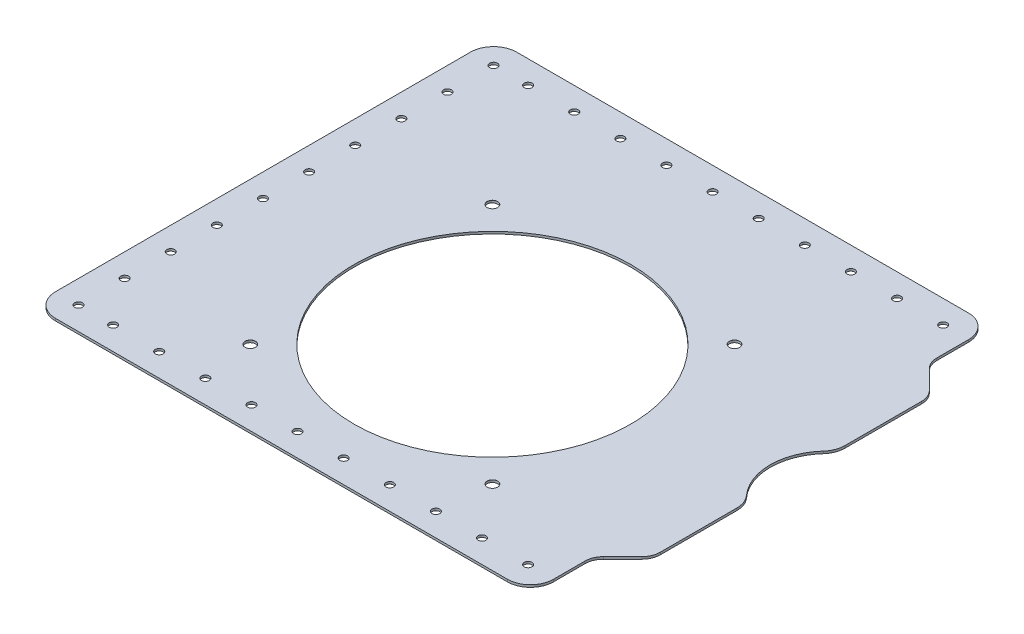
from build123d import *

# Parameters (mm, degrees)
SKETCH1_W                      = 229
SKETCH1_H                      = 200
BOSS_EXTRUDE1_DEPTH            = 1
CUT_EXTRUDE1_DEPTH             = 2
FILLET1_R                      = 8
FILLET2_R                      = 10
M3_CLEARANCE_HOLE1_AT_2_COUNT  = 2
M3_CLEARANCE_HOLE1_AT_2_PITCH  = 20
M3_CLEARANCE_HOLE1_AT_3_COUNT  = 2
M3_CLEARANCE_HOLE1_AT_3_PITCH  = 40
M3_CLEARANCE_HOLE1_AT_4_COUNT  = 2
M3_CLEARANCE_HOLE1_AT_4_PITCH  = 60
M3_CLEARANCE_HOLE1_AT_5_COUNT  = 2
M3_CLEARANCE_HOLE1_AT_5_PITCH  = 80
M3_CLEARANCE_HOLE1_AT_6_COUNT  = 2
M3_CLEARANCE_HOLE1_AT_6_PITCH  = 100
M3_CLEARANCE_HOLE1_AT_7_COUNT  = 2
M3_CLEARANCE_HOLE1_AT_7_PITCH  = 120
M3_CLEARANCE_HOLE1_AT_8_COUNT  = 2
M3_CLEARANCE_HOLE1_AT_8_PITCH  = 140
M3_CLEARANCE_HOLE1_AT_9_COUNT  = 2
M3_CLEARANCE_HOLE1_AT_9_PITCH  = 160
M3_CLEARANCE_HOLE1_AT_10_COUNT = 2
M3_CLEARANCE_HOLE1_AT_10_PITCH = 180
M3_CLEARANCE_HOLE2_AT_2_COUNT  = 2
M3_CLEARANCE_HOLE2_AT_2_PITCH  = 20
M3_CLEARANCE_HOLE2_AT_3_COUNT  = 2
M3_CLEARANCE_HOLE2_AT_3_PITCH  = 40
M3_CLEARANCE_HOLE2_AT_4_COUNT  = 2
M3_CLEARANCE_HOLE2_AT_4_PITCH  = 60
M3_CLEARANCE_HOLE2_AT_5_COUNT  = 2
M3_CLEARANCE_HOLE2_AT_5_PITCH  = 80
M3_CLEARANCE_HOLE2_AT_6_COUNT  = 2
M3_CLEARANCE_HOLE2_AT_6_PITCH  = 100
M3_CLEARANCE_HOLE2_AT_7_COUNT  = 2
M3_CLEARANCE_HOLE2_AT_7_PITCH  = 120
M3_CLEARANCE_HOLE2_AT_8_COUNT  = 2
M3_CLEARANCE_HOLE2_AT_8_PITCH  = 140
M3_CLEARANCE_HOLE2_AT_9_COUNT  = 2
M3_CLEARANCE_HOLE2_AT_9_PITCH  = 160
M3_CLEARANCE_HOLE2_AT_10_COUNT = 2
M3_CLEARANCE_HOLE2_AT_10_PITCH = 180
M3_CLEARANCE_HOLE2_AT_11_COUNT = 2
M3_CLEARANCE_HOLE2_AT_11_PITCH = 254.558441227
M3_CLEARANCE_HOLE2_AT_12_COUNT = 2
M3_CLEARANCE_HOLE2_AT_12_PITCH = 240.831891576
M3_CLEARANCE_HOLE2_AT_13_COUNT = 2
M3_CLEARANCE_HOLE2_AT_13_PITCH = 228.03508502
M3_CLEARANCE_HOLE2_AT_14_COUNT = 2
M3_CLEARANCE_HOLE2_AT_14_PITCH = 216.333076528
M3_CLEARANCE_HOLE2_AT_15_COUNT = 2
M3_CLEARANCE_HOLE2_AT_15_PITCH = 205.91260282
M3_CLEARANCE_HOLE2_AT_16_COUNT = 2
M3_CLEARANCE_HOLE2_AT_16_PITCH = 196.977156036
M3_CLEARANCE_HOLE2_AT_17_COUNT = 2
M3_CLEARANCE_HOLE2_AT_17_PITCH = 189.73665961
M3_CLEARANCE_HOLE2_AT_18_COUNT = 2
M3_CLEARANCE_HOLE2_AT_18_PITCH = 184.390889146
M3_CLEARANCE_HOLE2_AT_19_COUNT = 2
M3_CLEARANCE_HOLE2_AT_19_PITCH = 181.107702763
M3_CLEARANCE_HOLE2_AT_20_COUNT = 2
M3_CLEARANCE_HOLE2_AT_20_PITCH = 180
SKETCH7_R                      = 25
CUT_EXTRUDE2_DEPTH             = 10
FILLET3_R                      = 10
M4_CLEARANCE_HOLE1_AT_2_COUNT  = 2
M4_CLEARANCE_HOLE1_AT_2_PITCH  = 105
M4_CLEARANCE_HOLE1_AT_3_COUNT  = 2
M4_CLEARANCE_HOLE1_AT_3_PITCH  = 105
M4_CLEARANCE_HOLE1_AT_4_COUNT  = 2
M4_CLEARANCE_HOLE1_AT_4_PITCH  = 148.492424049
SKETCH10_R                     = 60
CUT_EXTRUDE3_DEPTH             = 10


with BuildPart() as part:
    # Sketch1 → Boss-Extrude1 (new body)
    with BuildSketch(Plane(origin=(0, 0, 0), x_dir=(1, 0, 0), z_dir=(0, 1, 0))):
        Rectangle(SKETCH1_W, SKETCH1_H)
    extrude(amount=BOSS_EXTRUDE1_DEPTH)

    # Sketch2 → Cut-Extrude1 (cut, through all)
    with BuildSketch(Plane(origin=(0, 1, 0), x_dir=(1, 0, 0), z_dir=(0, 1, 0))):
        Polygon((114.5, 60), (101.5, 73), (101.5, 100), (114.5, 100), align=None)
        Polygon((101.5, -100), (114.5, -100), (114.5, -60), (101.5, -73), align=None)
    extrude(amount=-CUT_EXTRUDE1_DEPTH, mode=Mode.SUBTRACT)

    # Fillet1
    fillet1_edges = [part.edges().sort_by_distance(p)[0] for p in [
        (114.5, 0.5, -60),
        (101.5, 0.5, -73),
        (101.5, 0.5, 73),
        (114.5, 0.5, 60),
    ]]
    fillet(fillet1_edges, radius=FILLET1_R)

    # Fillet2
    fillet2_edges = [part.edges().sort_by_distance(p)[0] for p in [
        (101.5, 0.5, -100),
        (101.5, 0.5, 100),
        (-114.5, 0.5, 100),
        (-114.5, 0.5, -100),
    ]]
    fillet(fillet2_edges, radius=FILLET2_R)

    # Sketch4 → M3 Clearance Hole1 (revolve, cut)
    with BuildSketch(Plane(origin=(-104.5, 0, -90), x_dir=(0, 0, -1), z_dir=(1, 0, 0))):
        Polygon((0, 0), (0, 1), (1.7, 1), (1.7, 0.025), (1.725, 0), align=None)
    m3_clearance_hole1 = revolve(axis=Axis((-104.5, -6.35, -90), (0, 1, 0)), mode=Mode.SUBTRACT)

    # M3 Clearance Hole1 at 2: M3 Clearance Hole1 ×2
    with Locations(*[(0, 0, i * M3_CLEARANCE_HOLE1_AT_2_PITCH) for i in range(1, M3_CLEARANCE_HOLE1_AT_2_COUNT)]):
        add(m3_clearance_hole1, mode=Mode.SUBTRACT)

    # M3 Clearance Hole1 at 3: M3 Clearance Hole1 ×2
    with Locations(*[(0, 0, i * M3_CLEARANCE_HOLE1_AT_3_PITCH) for i in range(1, M3_CLEARANCE_HOLE1_AT_3_COUNT)]):
        add(m3_clearance_hole1, mode=Mode.SUBTRACT)

    # M3 Clearance Hole1 at 4: M3 Clearance Hole1 ×2
    with Locations(*[(0, 0, i * M3_CLEARANCE_HOLE1_AT_4_PITCH) for i in range(1, M3_CLEARANCE_HOLE1_AT_4_COUNT)]):
        add(m3_clearance_hole1, mode=Mode.SUBTRACT)

    # M3 Clearance Hole1 at 5: M3 Clearance Hole1 ×2
    with Locations(*[(0, 0, i * M3_CLEARANCE_HOLE1_AT_5_PITCH) for i in range(1, M3_CLEARANCE_HOLE1_AT_5_COUNT)]):
        add(m3_clearance_hole1, mode=Mode.SUBTRACT)

    # M3 Clearance Hole1 at 6: M3 Clearance Hole1 ×2
    with Locations(*[(0, 0, i * M3_CLEARANCE_HOLE1_AT_6_PITCH) for i in range(1, M3_CLEARANCE_HOLE1_AT_6_COUNT)]):
        add(m3_clearance_hole1, mode=Mode.SUBTRACT)

    # M3 Clearance Hole1 at 7: M3 Clearance Hole1 ×2
    with Locations(*[(0, 0, i * M3_CLEARANCE_HOLE1_AT_7_PITCH) for i in range(1, M3_CLEARANCE_HOLE1_AT_7_COUNT)]):
        add(m3_clearance_hole1, mode=Mode.SUBTRACT)

    # M3 Clearance Hole1 at 8: M3 Clearance Hole1 ×2
    with Locations(*[(0, 0, i * M3_CLEARANCE_HOLE1_AT_8_PITCH) for i in range(1, M3_CLEARANCE_HOLE1_AT_8_COUNT)]):
        add(m3_clearance_hole1, mode=Mode.SUBTRACT)

    # M3 Clearance Hole1 at 9: M3 Clearance Hole1 ×2
    with Locations(*[(0, 0, i * M3_CLEARANCE_HOLE1_AT_9_PITCH) for i in range(1, M3_CLEARANCE_HOLE1_AT_9_COUNT)]):
        add(m3_clearance_hole1, mode=Mode.SUBTRACT)

    # M3 Clearance Hole1 at 10: M3 Clearance Hole1 ×2
    with Locations(*[(0, 0, i * M3_CLEARANCE_HOLE1_AT_10_PITCH) for i in range(1, M3_CLEARANCE_HOLE1_AT_10_COUNT)]):
        add(m3_clearance_hole1, mode=Mode.SUBTRACT)

    # Sketch6 → M3 Clearance Hole2 (revolve, cut)
    with BuildSketch(Plane(origin=(90.5, 0, -90), x_dir=(0, 0, -1), z_dir=(1, 0, 0))):
        Polygon((0, 0), (0, 1), (1.7, 1), (1.7, 0.025), (1.725, 0), align=None)
    m3_clearance_hole2 = revolve(axis=Axis((90.5, -6.35, -90), (0, 1, 0)), mode=Mode.SUBTRACT)

    # M3 Clearance Hole2 at 2: M3 Clearance Hole2 ×2
    with Locations(*[(-i * M3_CLEARANCE_HOLE2_AT_2_PITCH, 0, 0) for i in range(1, M3_CLEARANCE_HOLE2_AT_2_COUNT)]):
        add(m3_clearance_hole2, mode=Mode.SUBTRACT)

    # M3 Clearance Hole2 at 3: M3 Clearance Hole2 ×2
    with Locations(*[(-i * M3_CLEARANCE_HOLE2_AT_3_PITCH, 0, 0) for i in range(1, M3_CLEARANCE_HOLE2_AT_3_COUNT)]):
        add(m3_clearance_hole2, mode=Mode.SUBTRACT)

    # M3 Clearance Hole2 at 4: M3 Clearance Hole2 ×2
    with Locations(*[(-i * M3_CLEARANCE_HOLE2_AT_4_PITCH, 0, 0) for i in range(1, M3_CLEARANCE_HOLE2_AT_4_COUNT)]):
        add(m3_clearance_hole2, mode=Mode.SUBTRACT)

    # M3 Clearance Hole2 at 5: M3 Clearance Hole2 ×2
    with Locations(*[(-i * M3_CLEARANCE_HOLE2_AT_5_PITCH, 0, 0) for i in range(1, M3_CLEARANCE_HOLE2_AT_5_COUNT)]):
        add(m3_clearance_hole2, mode=Mode.SUBTRACT)

    # M3 Clearance Hole2 at 6: M3 Clearance Hole2 ×2
    with Locations(*[(-i * M3_CLEARANCE_HOLE2_AT_6_PITCH, 0, 0) for i in range(1, M3_CLEARANCE_HOLE2_AT_6_COUNT)]):
        add(m3_clearance_hole2, mode=Mode.SUBTRACT)

    # M3 Clearance Hole2 at 7: M3 Clearance Hole2 ×2
    with Locations(*[(-i * M3_CLEARANCE_HOLE2_AT_7_PITCH, 0, 0) for i in range(1, M3_CLEARANCE_HOLE2_AT_7_COUNT)]):
        add(m3_clearance_hole2, mode=Mode.SUBTRACT)

    # M3 Clearance Hole2 at 8: M3 Clearance Hole2 ×2
    with Locations(*[(-i * M3_CLEARANCE_HOLE2_AT_8_PITCH, 0, 0) for i in range(1, M3_CLEARANCE_HOLE2_AT_8_COUNT)]):
        add(m3_clearance_hole2, mode=Mode.SUBTRACT)

    # M3 Clearance Hole2 at 9: M3 Clearance Hole2 ×2
    with Locations(*[(-i * M3_CLEARANCE_HOLE2_AT_9_PITCH, 0, 0) for i in range(1, M3_CLEARANCE_HOLE2_AT_9_COUNT)]):
        add(m3_clearance_hole2, mode=Mode.SUBTRACT)

    # M3 Clearance Hole2 at 10: M3 Clearance Hole2 ×2
    with Locations(*[(-i * M3_CLEARANCE_HOLE2_AT_10_PITCH, 0, 0) for i in range(1, M3_CLEARANCE_HOLE2_AT_10_COUNT)]):
        add(m3_clearance_hole2, mode=Mode.SUBTRACT)

    # M3 Clearance Hole2 at 11: M3 Clearance Hole2 ×2
    with Locations(*[Vector(-0.707106781, 0, 0.707106781) * (i * M3_CLEARANCE_HOLE2_AT_11_PITCH) for i in range(1, M3_CLEARANCE_HOLE2_AT_11_COUNT)]):
        add(m3_clearance_hole2, mode=Mode.SUBTRACT)

    # M3 Clearance Hole2 at 12: M3 Clearance Hole2 ×2
    with Locations(*[Vector(-0.664363839, 0, 0.747409319) * (i * M3_CLEARANCE_HOLE2_AT_12_PITCH) for i in range(1, M3_CLEARANCE_HOLE2_AT_12_COUNT)]):
        add(m3_clearance_hole2, mode=Mode.SUBTRACT)

    # M3 Clearance Hole2 at 13: M3 Clearance Hole2 ×2
    with Locations(*[Vector(-0.613940614, 0, 0.789352217) * (i * M3_CLEARANCE_HOLE2_AT_13_PITCH) for i in range(1, M3_CLEARANCE_HOLE2_AT_13_COUNT)]):
        add(m3_clearance_hole2, mode=Mode.SUBTRACT)

    # M3 Clearance Hole2 at 14: M3 Clearance Hole2 ×2
    with Locations(*[Vector(-0.554700196, 0, 0.832050294) * (i * M3_CLEARANCE_HOLE2_AT_14_PITCH) for i in range(1, M3_CLEARANCE_HOLE2_AT_14_COUNT)]):
        add(m3_clearance_hole2, mode=Mode.SUBTRACT)

    # M3 Clearance Hole2 at 15: M3 Clearance Hole2 ×2
    with Locations(*[Vector(-0.485642931, 0, 0.874157276) * (i * M3_CLEARANCE_HOLE2_AT_15_PITCH) for i in range(1, M3_CLEARANCE_HOLE2_AT_15_COUNT)]):
        add(m3_clearance_hole2, mode=Mode.SUBTRACT)

    # M3 Clearance Hole2 at 16: M3 Clearance Hole2 ×2
    with Locations(*[Vector(-0.406138466, 0, 0.913811549) * (i * M3_CLEARANCE_HOLE2_AT_16_PITCH) for i in range(1, M3_CLEARANCE_HOLE2_AT_16_COUNT)]):
        add(m3_clearance_hole2, mode=Mode.SUBTRACT)

    # M3 Clearance Hole2 at 17: M3 Clearance Hole2 ×2
    with Locations(*[Vector(-0.316227766, 0, 0.948683298) * (i * M3_CLEARANCE_HOLE2_AT_17_PITCH) for i in range(1, M3_CLEARANCE_HOLE2_AT_17_COUNT)]):
        add(m3_clearance_hole2, mode=Mode.SUBTRACT)

    # M3 Clearance Hole2 at 18: M3 Clearance Hole2 ×2
    with Locations(*[Vector(-0.216930458, 0, 0.97618706) * (i * M3_CLEARANCE_HOLE2_AT_18_PITCH) for i in range(1, M3_CLEARANCE_HOLE2_AT_18_COUNT)]):
        add(m3_clearance_hole2, mode=Mode.SUBTRACT)

    # M3 Clearance Hole2 at 19: M3 Clearance Hole2 ×2
    with Locations(*[Vector(-0.110431526, 0, 0.993883735) * (i * M3_CLEARANCE_HOLE2_AT_19_PITCH) for i in range(1, M3_CLEARANCE_HOLE2_AT_19_COUNT)]):
        add(m3_clearance_hole2, mode=Mode.SUBTRACT)

    # M3 Clearance Hole2 at 20: M3 Clearance Hole2 ×2
    with Locations(*[(0, 0, i * M3_CLEARANCE_HOLE2_AT_20_PITCH) for i in range(1, M3_CLEARANCE_HOLE2_AT_20_COUNT)]):
        add(m3_clearance_hole2, mode=Mode.SUBTRACT)

    # Sketch7 → Cut-Extrude2 (cut)
    with BuildSketch(Plane(origin=(0, 0, 0), x_dir=(-1, 0, 0), z_dir=(0, -1, 0))):
        with Locations((-130.5, 0)):
            Circle(SKETCH7_R)
    extrude(amount=-CUT_EXTRUDE2_DEPTH, mode=Mode.SUBTRACT)

    # Fillet3
    fillet3_edges = [part.edges().sort_by_distance(p)[0] for p in [
        (114.5, 0.5, -19.209372712),
        (114.5, 0.5, 19.209372712),
    ]]
    fillet(fillet3_edges, radius=FILLET3_R)

    # Sketch9 → M4 Clearance Hole1 (revolve, cut)
    with BuildSketch(Plane(origin=(52.5, 1, -37.5), x_dir=(0, 0, 1), z_dir=(1, 0, 0))):
        Polygon((0, 0), (0, 1), (2.25, 1), (2.25, 0.025), (2.275, 0), align=None)
    m4_clearance_hole1 = revolve(axis=Axis((52.5, 7.35, -37.5), (0, -1, 0)), mode=Mode.SUBTRACT)

    # M4 Clearance Hole1 at 2: M4 Clearance Hole1 ×2
    with Locations(*[(0, 0, i * M4_CLEARANCE_HOLE1_AT_2_PITCH) for i in range(1, M4_CLEARANCE_HOLE1_AT_2_COUNT)]):
        add(m4_clearance_hole1, mode=Mode.SUBTRACT)

    # M4 Clearance Hole1 at 3: M4 Clearance Hole1 ×2
    with Locations(*[(-i * M4_CLEARANCE_HOLE1_AT_3_PITCH, 0, 0) for i in range(1, M4_CLEARANCE_HOLE1_AT_3_COUNT)]):
        add(m4_clearance_hole1, mode=Mode.SUBTRACT)

    # M4 Clearance Hole1 at 4: M4 Clearance Hole1 ×2
    with Locations(*[Vector(-0.707106781, 0, 0.707106781) * (i * M4_CLEARANCE_HOLE1_AT_4_PITCH) for i in range(1, M4_CLEARANCE_HOLE1_AT_4_COUNT)]):
        add(m4_clearance_hole1, mode=Mode.SUBTRACT)

    # Sketch10 → Cut-Extrude3 (cut)
    with BuildSketch(Plane(origin=(0, 1, 0), x_dir=(1, 0, 0), z_dir=(0, 1, 0))):
        with Locations((0, -15)):
            Circle(SKETCH10_R)
    extrude(amount=-CUT_EXTRUDE3_DEPTH, mode=Mode.SUBTRACT)


solid = part.part
